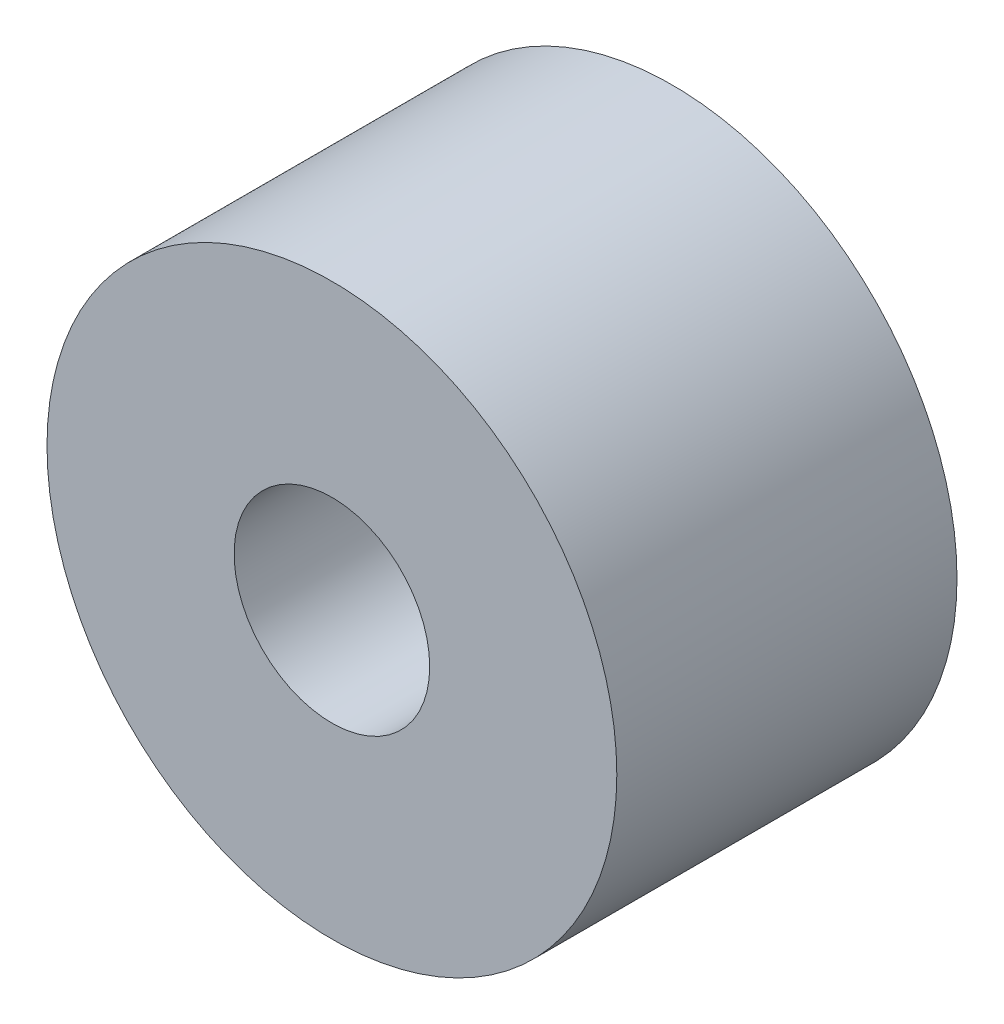
from build123d import *

# Parameters (mm, degrees)
SKETCH1_R           = 4.2545
SKETCH1_R_2         = 1.4605
BOSS_EXTRUDE1_DEPTH = 5.08


with BuildPart() as part:
    # Sketch1 → Boss-Extrude1 (new body)
    with BuildSketch(Plane.XY):
        Circle(SKETCH1_R)
        Circle(SKETCH1_R_2, mode=Mode.SUBTRACT)
    extrude(amount=BOSS_EXTRUDE1_DEPTH)


solid = part.part
